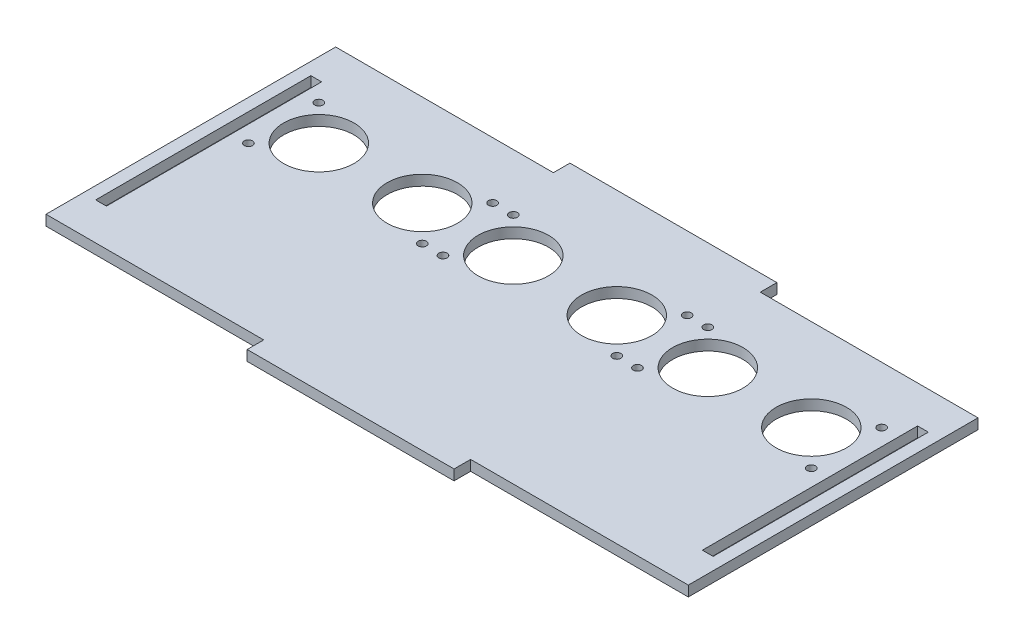
from build123d import *

# Parameters (mm, degrees)
SKETCH1_R           = 8.5
SKETCH1_R_2         = 1
SKETCH1_W           = 2.6
SKETCH1_H           = 52
BOSS_EXTRUDE1_DEPTH = 2.5


with BuildPart() as part:
    # Sketch1 → Boss-Extrude1 (new body)
    with BuildSketch(Plane(origin=(0, 0, 0), x_dir=(1, 0, 0), z_dir=(0, 1, 0))):
        Polygon((-25, 35), (-77.6, 35), (-77.6, -35), (-25, -35), (-25, -39), (25, -39), (25, -35), (77.6, -35), (77.6, 35), (25, 35), (25, 39), (-25, 39), align=None)
        with Locations((-12.5, 12.818198975)):
            Circle(SKETCH1_R, mode=Mode.SUBTRACT)
        with Locations((-21, 21.318198975)):
            Circle(SKETCH1_R_2, mode=Mode.SUBTRACT)
        with Locations((-21, 4.318198975)):
            Circle(SKETCH1_R_2, mode=Mode.SUBTRACT)
        with Locations((21, 4.318198975)):
            Circle(SKETCH1_R_2, mode=Mode.SUBTRACT)
        with Locations((21, 21.318198975)):
            Circle(SKETCH1_R_2, mode=Mode.SUBTRACT)
        with Locations((12.5, 12.818198975)):
            Circle(SKETCH1_R, mode=Mode.SUBTRACT)
        with Locations((26, 4.318198975)):
            Circle(SKETCH1_R_2, mode=Mode.SUBTRACT)
        with Locations((34.5, 12.818198975)):
            Circle(SKETCH1_R, mode=Mode.SUBTRACT)
        with Locations((26, 21.318198975)):
            Circle(SKETCH1_R_2, mode=Mode.SUBTRACT)
        with Locations((68, 21.318198975)):
            Circle(SKETCH1_R_2, mode=Mode.SUBTRACT)
        with Locations((68, 4.318198975)):
            Circle(SKETCH1_R_2, mode=Mode.SUBTRACT)
        with Locations((59.5, 12.818198975)):
            Circle(SKETCH1_R, mode=Mode.SUBTRACT)
        with Locations((-68, 4.318198975)):
            Circle(SKETCH1_R_2, mode=Mode.SUBTRACT)
        with Locations((-59.5, 12.818198975)):
            Circle(SKETCH1_R, mode=Mode.SUBTRACT)
        with Locations((-34.5, 12.818198975)):
            Circle(SKETCH1_R, mode=Mode.SUBTRACT)
        with Locations((-26, 21.318198975)):
            Circle(SKETCH1_R_2, mode=Mode.SUBTRACT)
        with Locations((-26, 4.318198975)):
            Circle(SKETCH1_R_2, mode=Mode.SUBTRACT)
        with Locations((-68, 21.318198975)):
            Circle(SKETCH1_R_2, mode=Mode.SUBTRACT)
        with Locations((-73.3, 0)):
            Rectangle(SKETCH1_W, SKETCH1_H, mode=Mode.SUBTRACT)
        with Locations((73.3, 0)):
            Rectangle(SKETCH1_W, SKETCH1_H, mode=Mode.SUBTRACT)
    extrude(amount=BOSS_EXTRUDE1_DEPTH)


solid = part.part
